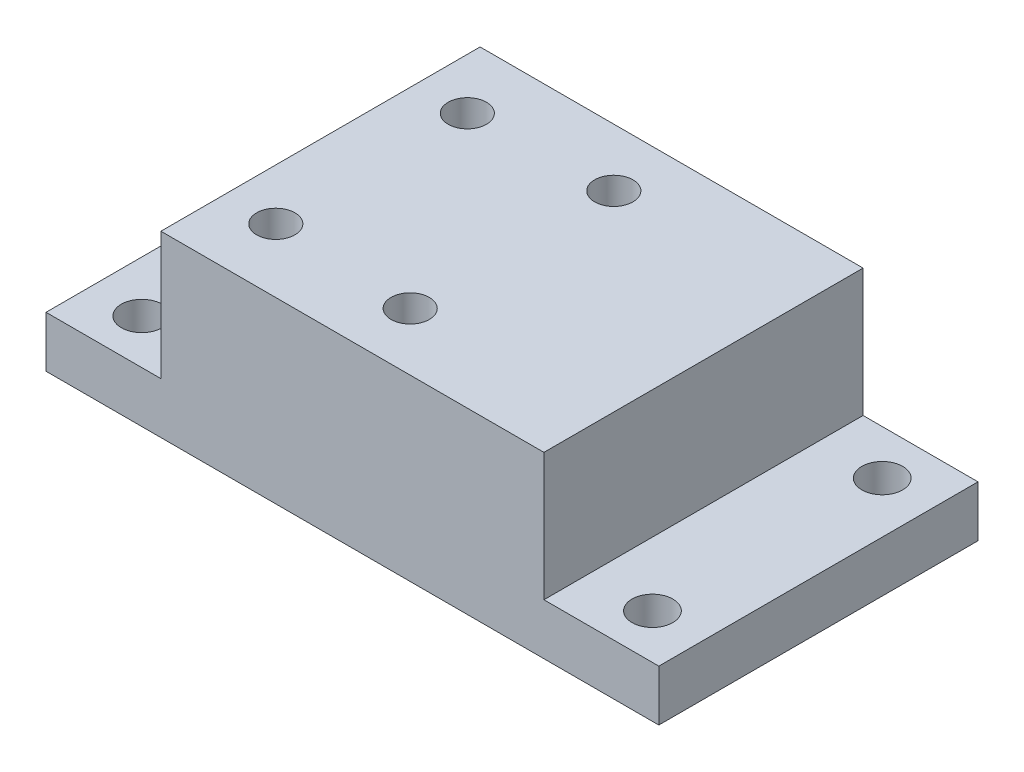
from build123d import *

# Parameters (mm, degrees)
SKETCH1_W           = 48
SKETCH1_H           = 25
BOSS_EXTRUDE1_DEPTH = 4
SKETCH2_W           = 30
SKETCH2_H           = 25
BOSS_EXTRUDE2_DEPTH = 10
SKETCH3_R           = 1.5
CUT_EXTRUDE1_DEPTH  = 15
SKETCH4_R           = 1.6
CUT_EXTRUDE2_DEPTH  = 15


with BuildPart() as part:
    # Sketch1 → Boss-Extrude1 (new body)
    with BuildSketch(Plane(origin=(0, 0, 0), x_dir=(1, 0, 0), z_dir=(0, 1, 0))):
        Rectangle(SKETCH1_W, SKETCH1_H)
    extrude(amount=BOSS_EXTRUDE1_DEPTH)

    # Sketch2 → Boss-Extrude2 (add)
    with BuildSketch(Plane(origin=(0, 4, 0), x_dir=(1, 0, 0), z_dir=(0, 1, 0))):
        Rectangle(SKETCH2_W, SKETCH2_H)
    extrude(amount=BOSS_EXTRUDE2_DEPTH)

    # Sketch3 → Cut-Extrude1 (cut, through all)
    with BuildSketch(Plane(origin=(0, 14, 0), x_dir=(1, 0, 0), z_dir=(0, 1, 0))):
        with Locations(Location((0, 7.975, 0), (0, 0, 270))):  # turned: the seam where the file's is
            Circle(SKETCH3_R)
        with Locations(Location((0, -7.975, 0), (0, 0, 270))):  # turned: the seam where the file's is
            Circle(SKETCH3_R)
        with Locations(Location((-11, 7.5, 0), (0, 0, 270))):  # turned: the seam where the file's is
            Circle(SKETCH3_R)
        with Locations(Location((-11, -7.5, 0), (0, 0, 270))):  # turned: the seam where the file's is
            Circle(SKETCH3_R)
    extrude(amount=-CUT_EXTRUDE1_DEPTH, mode=Mode.SUBTRACT)

    # Sketch4 → Cut-Extrude2 (cut, through all)
    with BuildSketch(Plane.XZ):
        with Locations(Location((-20, 9, 0), (0, 0, 270))):  # turned: the seam where the file's is
            Circle(SKETCH4_R)
        with Locations(Location((20, 9, 0), (0, 0, 270))):  # turned: the seam where the file's is
            Circle(SKETCH4_R)
        with Locations(Location((20, -9, 0), (0, 0, 270))):  # turned: the seam where the file's is
            Circle(SKETCH4_R)
        with Locations(Location((-20, -9, 0), (0, 0, 270))):  # turned: the seam where the file's is
            Circle(SKETCH4_R)
    extrude(amount=-CUT_EXTRUDE2_DEPTH, mode=Mode.SUBTRACT)


solid = part.part
